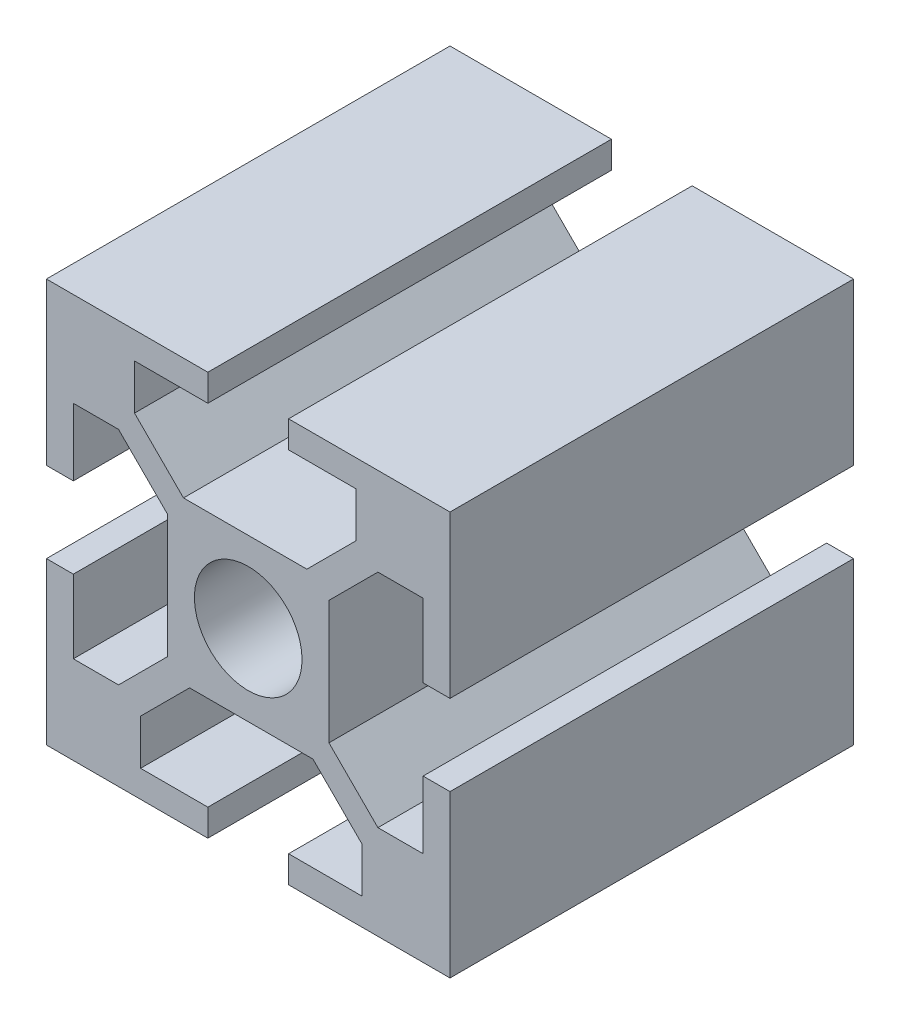
from build123d import *

# Parameters (mm, degrees)
SKETCH2_R           = 4
BOSS_EXTRUDE2_DEPTH = 30


with BuildPart() as part:
    # Sketch2 → Boss-Extrude2 (new body)
    with BuildSketch(Plane.XY):
        Polygon((4.359955816, 6), (-4.81161706, 6), (-8.451661244, 9.640044184), (-8.451661244, 13), (-3, 13), (-3, 15), (-15, 15), (-15, 3), (-13, 3), (-13, 8), (-9.640044184, 8), (-6, 4.359955816), (-6, -4.81161706), (-9.640044184, -8.451661244), (-13, -8.451661244), (-13, -3), (-15, -3), (-15, -15), (-3, -15), (-3, -13), (-8, -13), (-8, -9.640044184), (-4.359955816, -6), (4.81161706, -6), (8.451661244, -9.640044184), (8.451661244, -13), (3, -13), (3, -15), (15, -15), (15, -3), (13, -3), (13, -8), (9.640044184, -8), (6, -4.359955816), (6, 4.81161706), (9.640044184, 8.451661244), (13, 8.451661244), (13, 3), (15, 3), (15, 15), (3, 15), (3, 13), (8, 13), (8, 9.640044184), align=None)
        Circle(SKETCH2_R, mode=Mode.SUBTRACT)
    extrude(amount=BOSS_EXTRUDE2_DEPTH)


solid = part.part
